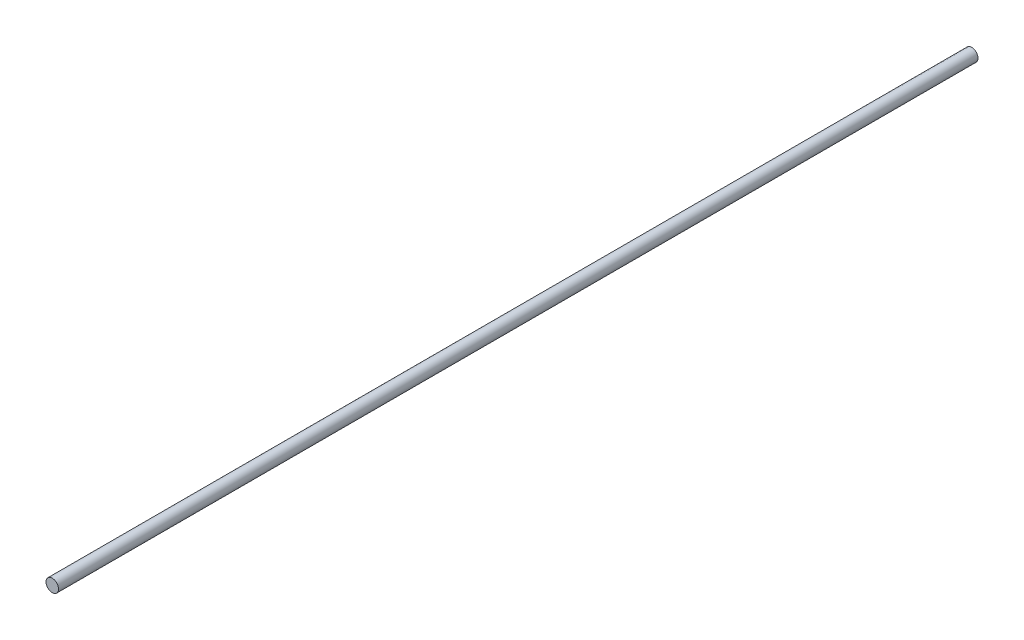
from build123d import *

# Parameters (mm, degrees)
SKETCH1_R           = 5
BOSS_EXTRUDE1_DEPTH = 733


with BuildPart() as part:
    # Sketch1 → Boss-Extrude1 (new body)
    with BuildSketch(Plane.XY):
        Circle(SKETCH1_R)
    extrude(amount=BOSS_EXTRUDE1_DEPTH)


solid = part.part
